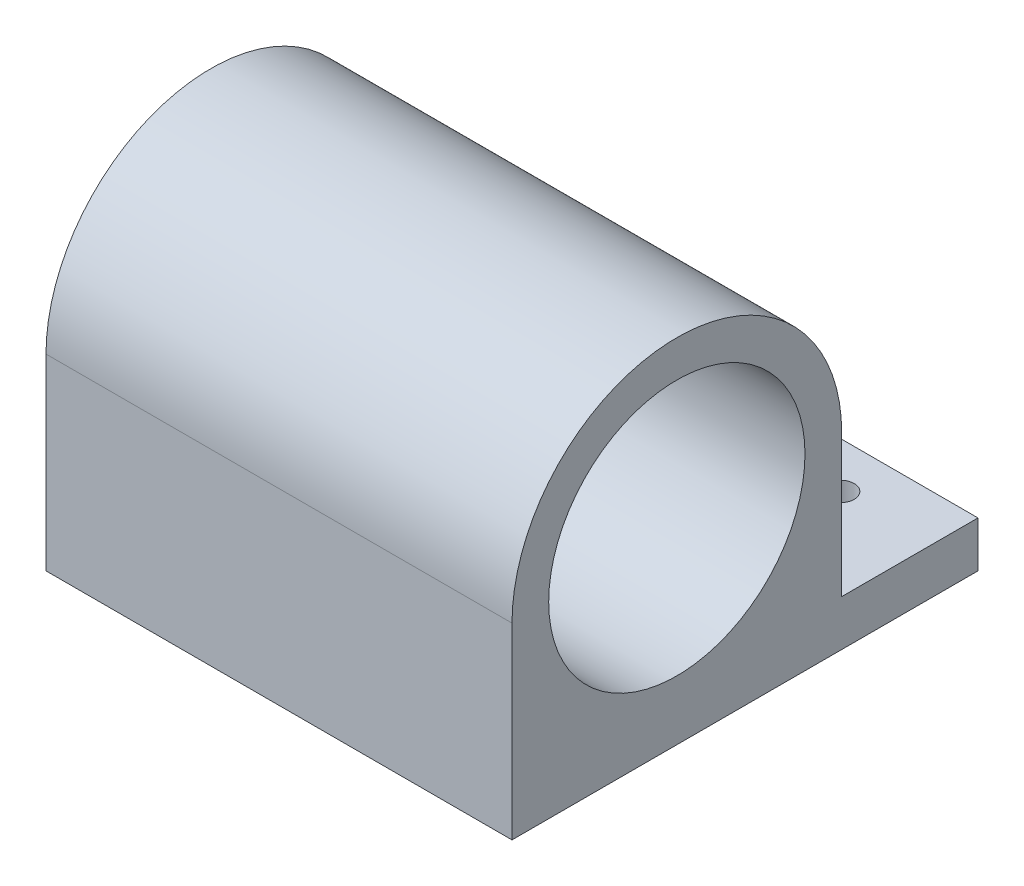
from build123d import *

# Parameters (mm, degrees)
SKETCH1_W           = 50.8
SKETCH1_H           = 50.8
SKETCH1_R           = 1.5
BOSS_EXTRUDE1_DEPTH = 5
BOSS_EXTRUDE2_DEPTH = 50.8


with BuildPart() as part:
    # Sketch1 → Boss-Extrude1 (new body)
    with BuildSketch(Plane(origin=(0, 0, 0), x_dir=(1, 0, 0), z_dir=(0, 1, 0))):
        with Locations((25.4, 25.4)):
            Rectangle(SKETCH1_W, SKETCH1_H)
        with Locations((10, 45.8)):
            Circle(SKETCH1_R, mode=Mode.SUBTRACT)
        with Locations((40.8, 45.8)):
            Circle(SKETCH1_R, mode=Mode.SUBTRACT)
    extrude(amount=BOSS_EXTRUDE1_DEPTH)

    # Sketch2 → Boss-Extrude2 (add)
    with BuildSketch(Plane.ZY):
        with BuildLine():
            ThreePointArc((-27.113303561, 5), (-33.578107909, 11.564503523), (-35.94, 20.47))
            Line((-35.94, 20.47), (-35.94, 5))
            Line((-35.94, 5), (-27.113303561, 5))
        make_face()
        with BuildLine():
            Line((0, 5), (0, 20.47))
            ThreePointArc((0, 20.47), (-2.361892091, 11.564503523), (-8.826696439, 5))
            Line((-8.826696439, 5), (0, 5))
        make_face()
        with BuildLine():
            Line((-31.94, 20.47), (-35.94, 20.47))
            ThreePointArc((-35.94, 20.47), (-33.578107909, 11.564503523), (-27.113303561, 5))
            Line((-27.113303561, 5), (-8.826696439, 5))
            ThreePointArc((-8.826696439, 5), (-2.361892091, 11.564503523), (0, 20.47))
            Line((0, 20.47), (-4, 20.47))
            ThreePointArc((-4, 20.47), (-17.97, 6.5), (-31.94, 20.47))
        make_face()
        with BuildLine():
            ThreePointArc((0, 20.47), (-17.97, 38.44), (-35.94, 20.47))
            Line((-35.94, 20.47), (-31.94, 20.47))
            ThreePointArc((-31.94, 20.47), (-17.97, 34.44), (-4, 20.47))
            Line((-4, 20.47), (0, 20.47))
        make_face()
    extrude(amount=-BOSS_EXTRUDE2_DEPTH)


solid = part.part
